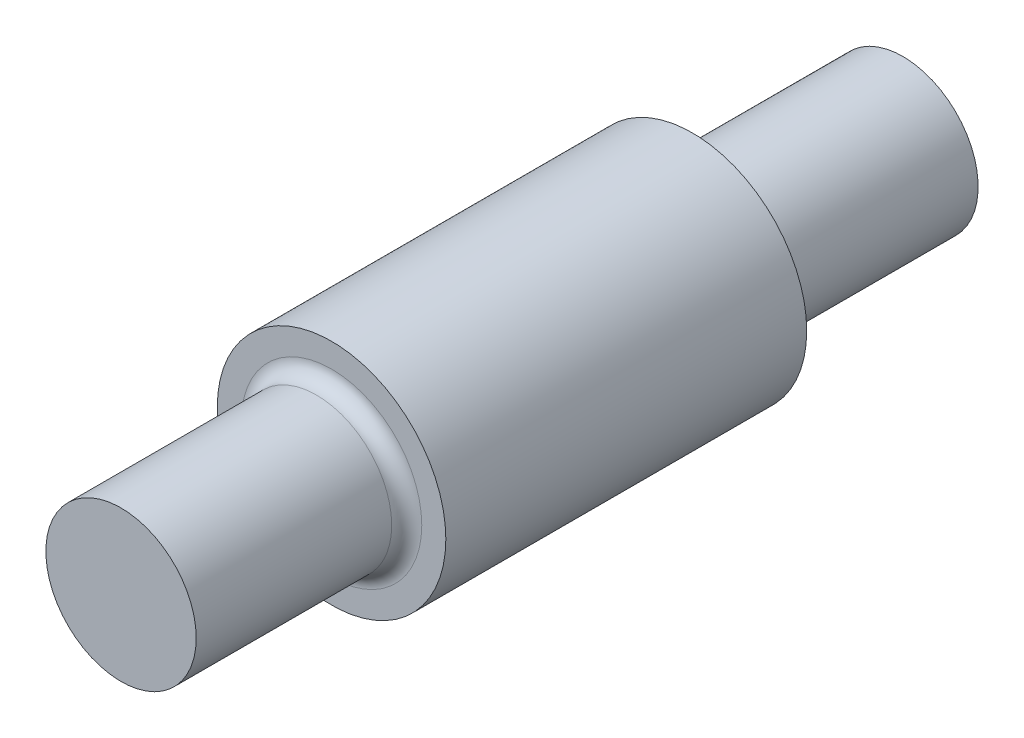
from build123d import *

# Parameters (mm, degrees)
SKETCH1_R           = 19
BOSS_EXTRUDE1_DEPTH = 130
SKETCH2_R           = 19
SKETCH2_R_2         = 12.5
CUT_EXTRUDE2_DEPTH  = 35
SKETCH3_R           = 19
SKETCH3_R_2         = 12.5
CUT_EXTRUDE3_DEPTH  = 35
FILLET1_R           = 2.5


with BuildPart() as part:
    # Sketch1 → Boss-Extrude1 (new body)
    with BuildSketch(Plane.XY):
        Circle(SKETCH1_R)
    extrude(amount=BOSS_EXTRUDE1_DEPTH)

    # Sketch2 → Cut-Extrude2 (cut)
    with BuildSketch(Plane.XY.offset(130)):
        Circle(SKETCH2_R)
        Circle(SKETCH2_R_2, mode=Mode.SUBTRACT)
    extrude(amount=-CUT_EXTRUDE2_DEPTH, mode=Mode.SUBTRACT)

    # Sketch3 → Cut-Extrude3 (cut)
    with BuildSketch(Plane(origin=(0, 0, 0), x_dir=(-1, 0, 0), z_dir=(0, 0, -1))):
        Circle(SKETCH3_R)
        Circle(SKETCH3_R_2, mode=Mode.SUBTRACT)
    extrude(amount=-CUT_EXTRUDE3_DEPTH, mode=Mode.SUBTRACT)

    # Fillet1
    fillet1_edges = [part.edges().sort_by_distance(p)[0] for p in [
        (12.5, 0, 35),
        (-12.5, 0, 95),
    ]]
    fillet(fillet1_edges, radius=FILLET1_R)


solid = part.part
